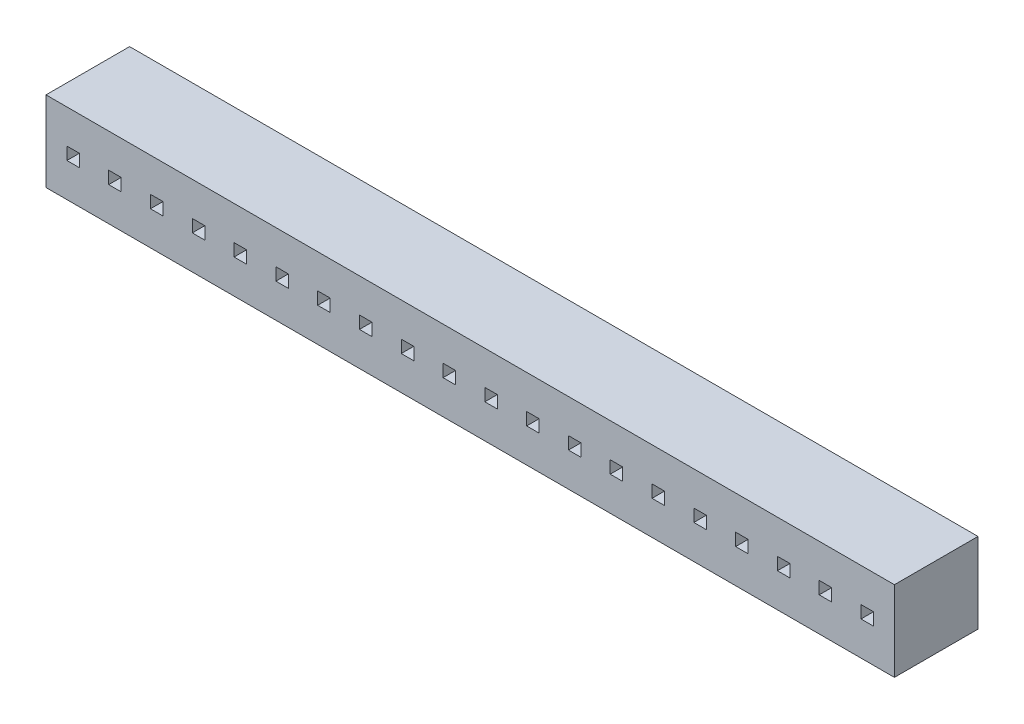
from build123d import *

# Parameters (mm, degrees)
SKETCH1_W           = 25.78
SKETCH1_H           = 2.54
BOSS_EXTRUDE1_DEPTH = 2.44
CUT_EXTRUDE1_REACH  = 4.54
SKETCH2_W           = 0.38
SKETCH2_H           = 0.38


with BuildPart() as part:
    # Sketch1 → Boss-Extrude1 (new body)
    with BuildSketch(Plane(origin=(0, 0, 0), x_dir=(1, 0, 0), z_dir=(0, 1, 0))):
        Rectangle(SKETCH1_W, SKETCH1_H)
    extrude(amount=BOSS_EXTRUDE1_DEPTH)

    # Sketch2 → Cut-Extrude1 (cut, up to next)
    with BuildSketch(Plane.XY.offset(1.27), mode=Mode.PRIVATE) as cut_extrude1_sk1:
        with Locations((-10.795, 1.22)):
            Rectangle(SKETCH2_W, SKETCH2_H)
    cut_extrude1_tool1 = extrude(cut_extrude1_sk1.sketch, amount=-CUT_EXTRUDE1_REACH, mode=Mode.PRIVATE) & part.part
    add(cut_extrude1_tool1.solids().sort_by_distance((-10.795, 1.22, 1.27))[0], mode=Mode.SUBTRACT)
    # Sketch2 → Cut-Extrude1 (cut, up to next)
    with BuildSketch(Plane.XY.offset(1.27), mode=Mode.PRIVATE) as cut_extrude1_sk2:
        with Locations((-12.065, 1.22)):
            Rectangle(SKETCH2_W, SKETCH2_H)
    cut_extrude1_tool2 = extrude(cut_extrude1_sk2.sketch, amount=-CUT_EXTRUDE1_REACH, mode=Mode.PRIVATE) & part.part
    add(cut_extrude1_tool2.solids().sort_by_distance((-12.065, 1.22, 1.27))[0], mode=Mode.SUBTRACT)
    # Sketch2 → Cut-Extrude1 (cut, up to next)
    with BuildSketch(Plane.XY.offset(1.27), mode=Mode.PRIVATE) as cut_extrude1_sk3:
        with Locations((-9.525, 1.22)):
            Rectangle(SKETCH2_W, SKETCH2_H)
    cut_extrude1_tool3 = extrude(cut_extrude1_sk3.sketch, amount=-CUT_EXTRUDE1_REACH, mode=Mode.PRIVATE) & part.part
    add(cut_extrude1_tool3.solids().sort_by_distance((-9.525, 1.22, 1.27))[0], mode=Mode.SUBTRACT)
    # Sketch2 → Cut-Extrude1 (cut, up to next)
    with BuildSketch(Plane.XY.offset(1.27), mode=Mode.PRIVATE) as cut_extrude1_sk4:
        with Locations((-8.255, 1.22)):
            Rectangle(SKETCH2_W, SKETCH2_H)
    cut_extrude1_tool4 = extrude(cut_extrude1_sk4.sketch, amount=-CUT_EXTRUDE1_REACH, mode=Mode.PRIVATE) & part.part
    add(cut_extrude1_tool4.solids().sort_by_distance((-8.255, 1.22, 1.27))[0], mode=Mode.SUBTRACT)
    # Sketch2 → Cut-Extrude1 (cut, up to next)
    with BuildSketch(Plane.XY.offset(1.27), mode=Mode.PRIVATE) as cut_extrude1_sk5:
        with Locations((-6.985, 1.22)):
            Rectangle(SKETCH2_W, SKETCH2_H)
    cut_extrude1_tool5 = extrude(cut_extrude1_sk5.sketch, amount=-CUT_EXTRUDE1_REACH, mode=Mode.PRIVATE) & part.part
    add(cut_extrude1_tool5.solids().sort_by_distance((-6.985, 1.22, 1.27))[0], mode=Mode.SUBTRACT)
    # Sketch2 → Cut-Extrude1 (cut, up to next)
    with BuildSketch(Plane.XY.offset(1.27), mode=Mode.PRIVATE) as cut_extrude1_sk6:
        with Locations((-5.715, 1.22)):
            Rectangle(SKETCH2_W, SKETCH2_H)
    cut_extrude1_tool6 = extrude(cut_extrude1_sk6.sketch, amount=-CUT_EXTRUDE1_REACH, mode=Mode.PRIVATE) & part.part
    add(cut_extrude1_tool6.solids().sort_by_distance((-5.715, 1.22, 1.27))[0], mode=Mode.SUBTRACT)
    # Sketch2 → Cut-Extrude1 (cut, up to next)
    with BuildSketch(Plane.XY.offset(1.27), mode=Mode.PRIVATE) as cut_extrude1_sk7:
        with Locations((-4.445, 1.22)):
            Rectangle(SKETCH2_W, SKETCH2_H)
    cut_extrude1_tool7 = extrude(cut_extrude1_sk7.sketch, amount=-CUT_EXTRUDE1_REACH, mode=Mode.PRIVATE) & part.part
    add(cut_extrude1_tool7.solids().sort_by_distance((-4.445, 1.22, 1.27))[0], mode=Mode.SUBTRACT)
    # Sketch2 → Cut-Extrude1 (cut, up to next)
    with BuildSketch(Plane.XY.offset(1.27), mode=Mode.PRIVATE) as cut_extrude1_sk8:
        with Locations((-3.175, 1.22)):
            Rectangle(SKETCH2_W, SKETCH2_H)
    cut_extrude1_tool8 = extrude(cut_extrude1_sk8.sketch, amount=-CUT_EXTRUDE1_REACH, mode=Mode.PRIVATE) & part.part
    add(cut_extrude1_tool8.solids().sort_by_distance((-3.175, 1.22, 1.27))[0], mode=Mode.SUBTRACT)
    # Sketch2 → Cut-Extrude1 (cut, up to next)
    with BuildSketch(Plane.XY.offset(1.27), mode=Mode.PRIVATE) as cut_extrude1_sk9:
        with Locations((-1.905, 1.22)):
            Rectangle(SKETCH2_W, SKETCH2_H)
    cut_extrude1_tool9 = extrude(cut_extrude1_sk9.sketch, amount=-CUT_EXTRUDE1_REACH, mode=Mode.PRIVATE) & part.part
    add(cut_extrude1_tool9.solids().sort_by_distance((-1.905, 1.22, 1.27))[0], mode=Mode.SUBTRACT)
    # Sketch2 → Cut-Extrude1 (cut, up to next)
    with BuildSketch(Plane.XY.offset(1.27), mode=Mode.PRIVATE) as cut_extrude1_sk10:
        with Locations((-0.635, 1.22)):
            Rectangle(SKETCH2_W, SKETCH2_H)
    cut_extrude1_tool10 = extrude(cut_extrude1_sk10.sketch, amount=-CUT_EXTRUDE1_REACH, mode=Mode.PRIVATE) & part.part
    add(cut_extrude1_tool10.solids().sort_by_distance((-0.635, 1.22, 1.27))[0], mode=Mode.SUBTRACT)
    # Sketch2 → Cut-Extrude1 (cut, up to next)
    with BuildSketch(Plane.XY.offset(1.27), mode=Mode.PRIVATE) as cut_extrude1_sk11:
        with Locations((0.635, 1.22)):
            Rectangle(SKETCH2_W, SKETCH2_H)
    cut_extrude1_tool11 = extrude(cut_extrude1_sk11.sketch, amount=-CUT_EXTRUDE1_REACH, mode=Mode.PRIVATE) & part.part
    add(cut_extrude1_tool11.solids().sort_by_distance((0.635, 1.22, 1.27))[0], mode=Mode.SUBTRACT)
    # Sketch2 → Cut-Extrude1 (cut, up to next)
    with BuildSketch(Plane.XY.offset(1.27), mode=Mode.PRIVATE) as cut_extrude1_sk12:
        with Locations((1.905, 1.22)):
            Rectangle(SKETCH2_W, SKETCH2_H)
    cut_extrude1_tool12 = extrude(cut_extrude1_sk12.sketch, amount=-CUT_EXTRUDE1_REACH, mode=Mode.PRIVATE) & part.part
    add(cut_extrude1_tool12.solids().sort_by_distance((1.905, 1.22, 1.27))[0], mode=Mode.SUBTRACT)
    # Sketch2 → Cut-Extrude1 (cut, up to next)
    with BuildSketch(Plane.XY.offset(1.27), mode=Mode.PRIVATE) as cut_extrude1_sk13:
        with Locations((3.175, 1.22)):
            Rectangle(SKETCH2_W, SKETCH2_H)
    cut_extrude1_tool13 = extrude(cut_extrude1_sk13.sketch, amount=-CUT_EXTRUDE1_REACH, mode=Mode.PRIVATE) & part.part
    add(cut_extrude1_tool13.solids().sort_by_distance((3.175, 1.22, 1.27))[0], mode=Mode.SUBTRACT)
    # Sketch2 → Cut-Extrude1 (cut, up to next)
    with BuildSketch(Plane.XY.offset(1.27), mode=Mode.PRIVATE) as cut_extrude1_sk14:
        with Locations((4.445, 1.22)):
            Rectangle(SKETCH2_W, SKETCH2_H)
    cut_extrude1_tool14 = extrude(cut_extrude1_sk14.sketch, amount=-CUT_EXTRUDE1_REACH, mode=Mode.PRIVATE) & part.part
    add(cut_extrude1_tool14.solids().sort_by_distance((4.445, 1.22, 1.27))[0], mode=Mode.SUBTRACT)
    # Sketch2 → Cut-Extrude1 (cut, up to next)
    with BuildSketch(Plane.XY.offset(1.27), mode=Mode.PRIVATE) as cut_extrude1_sk15:
        with Locations((5.715, 1.22)):
            Rectangle(SKETCH2_W, SKETCH2_H)
    cut_extrude1_tool15 = extrude(cut_extrude1_sk15.sketch, amount=-CUT_EXTRUDE1_REACH, mode=Mode.PRIVATE) & part.part
    add(cut_extrude1_tool15.solids().sort_by_distance((5.715, 1.22, 1.27))[0], mode=Mode.SUBTRACT)
    # Sketch2 → Cut-Extrude1 (cut, up to next)
    with BuildSketch(Plane.XY.offset(1.27), mode=Mode.PRIVATE) as cut_extrude1_sk16:
        with Locations((6.985, 1.22)):
            Rectangle(SKETCH2_W, SKETCH2_H)
    cut_extrude1_tool16 = extrude(cut_extrude1_sk16.sketch, amount=-CUT_EXTRUDE1_REACH, mode=Mode.PRIVATE) & part.part
    add(cut_extrude1_tool16.solids().sort_by_distance((6.985, 1.22, 1.27))[0], mode=Mode.SUBTRACT)
    # Sketch2 → Cut-Extrude1 (cut, up to next)
    with BuildSketch(Plane.XY.offset(1.27), mode=Mode.PRIVATE) as cut_extrude1_sk17:
        with Locations((8.255, 1.22)):
            Rectangle(SKETCH2_W, SKETCH2_H)
    cut_extrude1_tool17 = extrude(cut_extrude1_sk17.sketch, amount=-CUT_EXTRUDE1_REACH, mode=Mode.PRIVATE) & part.part
    add(cut_extrude1_tool17.solids().sort_by_distance((8.255, 1.22, 1.27))[0], mode=Mode.SUBTRACT)
    # Sketch2 → Cut-Extrude1 (cut, up to next)
    with BuildSketch(Plane.XY.offset(1.27), mode=Mode.PRIVATE) as cut_extrude1_sk18:
        with Locations((9.525, 1.22)):
            Rectangle(SKETCH2_W, SKETCH2_H)
    cut_extrude1_tool18 = extrude(cut_extrude1_sk18.sketch, amount=-CUT_EXTRUDE1_REACH, mode=Mode.PRIVATE) & part.part
    add(cut_extrude1_tool18.solids().sort_by_distance((9.525, 1.22, 1.27))[0], mode=Mode.SUBTRACT)
    # Sketch2 → Cut-Extrude1 (cut, up to next)
    with BuildSketch(Plane.XY.offset(1.27), mode=Mode.PRIVATE) as cut_extrude1_sk19:
        with Locations((10.795, 1.22)):
            Rectangle(SKETCH2_W, SKETCH2_H)
    cut_extrude1_tool19 = extrude(cut_extrude1_sk19.sketch, amount=-CUT_EXTRUDE1_REACH, mode=Mode.PRIVATE) & part.part
    add(cut_extrude1_tool19.solids().sort_by_distance((10.795, 1.22, 1.27))[0], mode=Mode.SUBTRACT)
    # Sketch2 → Cut-Extrude1 (cut, up to next)
    with BuildSketch(Plane.XY.offset(1.27), mode=Mode.PRIVATE) as cut_extrude1_sk20:
        with Locations((12.065, 1.22)):
            Rectangle(SKETCH2_W, SKETCH2_H)
    cut_extrude1_tool20 = extrude(cut_extrude1_sk20.sketch, amount=-CUT_EXTRUDE1_REACH, mode=Mode.PRIVATE) & part.part
    add(cut_extrude1_tool20.solids().sort_by_distance((12.065, 1.22, 1.27))[0], mode=Mode.SUBTRACT)


solid = part.part
